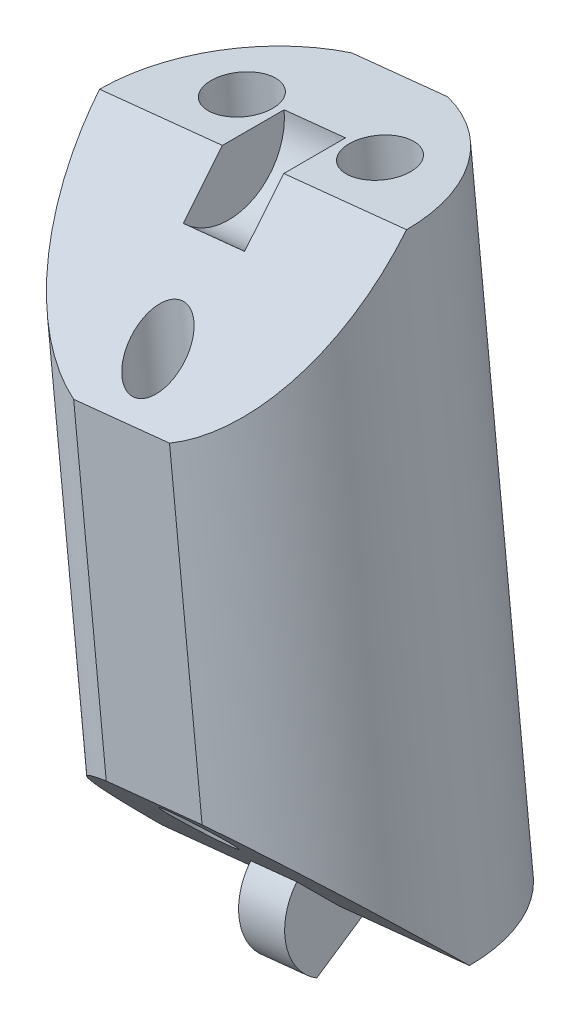
from build123d import *

# Parameters (mm, degrees)
SKETCH3_R               = 8
BOSS_EXTRUDE1_DEPTH     = 31.578947368
CUT_EXTRUDE1_DEPTH      = 12.240009257
CUT_EXTRUDE1_DEPTH_BACK = 12.240009257
BOSS_EXTRUDE2_DEPTH     = 1.2
CUT_EXTRUDE2_DEPTH      = 1.6
SKETCH8_R               = 1.4
SKETCH8_R_2             = 1.6
CUT_EXTRUDE3_DEPTH      = 2.64160469
CUT_EXTRUDE3_DEPTH_BACK = 35.921940493
CUT_EXTRUDE4_DEPTH      = 35.921940493


with BuildPart() as part:
    # Sketch3 → Boss-Extrude1 (new body)
    with BuildSketch(Plane(origin=(-20.344467381, 196.178792599, 0), x_dir=(-0.994665758, -0.103150523, 0), z_dir=(0.103150523, -0.994665758, 0))):
        with Locations((-10.431405186, 0)):
            Circle(SKETCH3_R)
    extrude(amount=BOSS_EXTRUDE1_DEPTH)

    # Sketch4 → Cut-Extrude1 (cut, two sides)
    with BuildSketch(Plane(origin=(10.375761543, 1.076004901, 0), x_dir=(0.103150523, -0.994665758, 0), z_dir=(-0.994665758, -0.103150523, 0))) as cut_extrude1_sk:
        Polygon((-197.230869842, 0), (-189.230869842, 8), (-197.230869842, 8), align=None)
        Polygon((-173.651922474, 8), (-165.651922474, 8), (-165.651922474, 0), align=None)
    extrude(amount=CUT_EXTRUDE1_DEPTH, mode=Mode.SUBTRACT)
    extrude(cut_extrude1_sk.sketch, amount=-CUT_EXTRUDE1_DEPTH_BACK, mode=Mode.SUBTRACT)

    # Sketch5 → Boss-Extrude2 (add, symmetric)
    with BuildSketch(Plane(origin=(10.375761543, 1.076004901, 0), x_dir=(0.103150523, -0.994665758, 0), z_dir=(-0.994665758, -0.103150523, 0))):
        with BuildLine():
            Line((-165.651922474, -2.8), (-163.227051343, 1.4))
            ThreePointArc((-163.227051343, 1.4), (-165.286449135, 2.776045612), (-167.631821461, 1.979898987))
            Line((-167.631821461, 1.979898987), (-165.651922474, 0))
            Line((-165.651922474, 0), (-165.651922474, -2.8))
        make_face()
    extrude(amount=BOSS_EXTRUDE2_DEPTH, both=True)

    # Sketch7 → Cut-Extrude2 (cut, symmetric)
    with BuildSketch(Plane(origin=(10.375761543, 1.076004901, 0), x_dir=(0.103150523, -0.994665758, 0), z_dir=(-0.994665758, -0.103150523, 0))):
        with BuildLine():
            Line((-194.968128142, 2.2627417), (-197.230869842, 0))
            Line((-197.230869842, 0), (-197.230869842, -3.2))
            ThreePointArc((-197.230869842, -3.2), (-194.274455338, -1.224586984), (-194.968128142, 2.2627417))
        make_face()
    extrude(amount=CUT_EXTRUDE2_DEPTH, both=True, mode=Mode.SUBTRACT)

    # Sketch8 → Cut-Extrude3 (cut, two sides)
    with BuildSketch(Plane(origin=(-20.344467381, 196.178792599, 0), x_dir=(0.994665758, 0.103150523, 0), z_dir=(-0.103150523, 0.994665758, 0))) as cut_extrude3_sk:
        with Locations((10.431405186, -5.5)):
            Circle(SKETCH8_R)
        with Locations((6.831405186, 3)):
            Circle(SKETCH8_R_2)
        with Locations((14.031405186, 3)):
            Circle(SKETCH8_R_2)
    extrude(amount=CUT_EXTRUDE3_DEPTH, mode=Mode.SUBTRACT)
    extrude(cut_extrude3_sk.sketch, amount=-CUT_EXTRUDE3_DEPTH_BACK, mode=Mode.SUBTRACT)

    # Sketch9 → Cut-Extrude4 (cut, through all)
    with BuildSketch(Plane(origin=(-20.344467381, 196.178792599, 0), x_dir=(0.994665758, 0.103150523, 0), z_dir=(-0.103150523, 0.994665758, 0))):
        with BuildLine():
            Line((7.933405986, 7.6), (12.929404385, 7.6))
            ThreePointArc((12.929404385, 7.6), (10.431405186, 8), (7.933405986, 7.6))
        make_face()
        with BuildLine():
            Line((7.933405986, -7.6), (12.929404385, -7.6))
            ThreePointArc((12.929404385, -7.6), (10.431405186, -8), (7.933405986, -7.6))
        make_face()
    extrude(amount=-CUT_EXTRUDE4_DEPTH, mode=Mode.SUBTRACT)


solid = part.part
